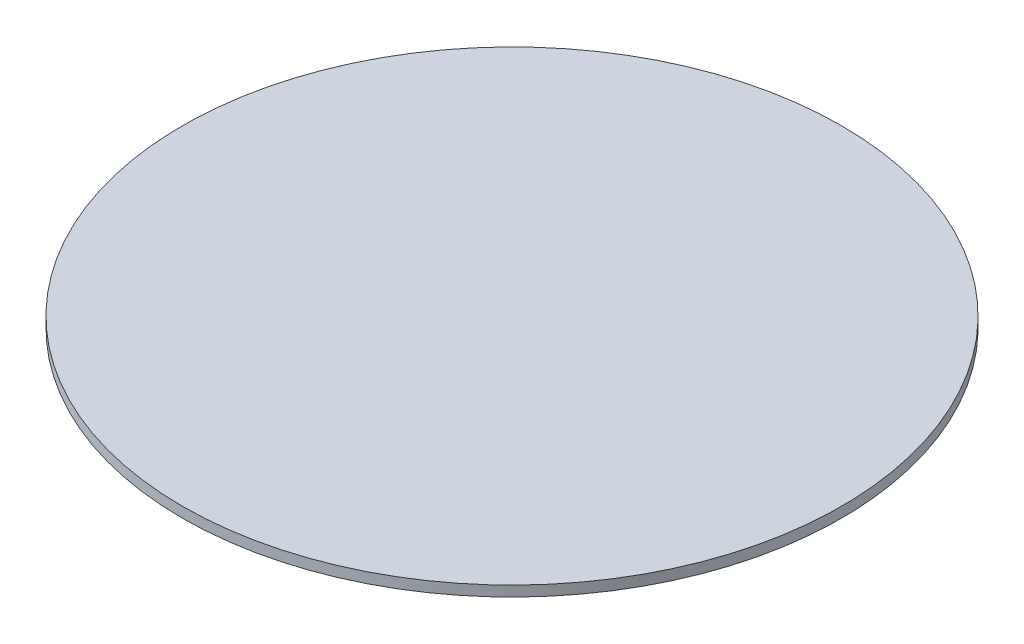
from build123d import *

# Parameters (mm, degrees)
SKETCH1_R           = 158.75
BOSS_EXTRUDE1_DEPTH = 5


with BuildPart() as part:
    # Sketch1 → Boss-Extrude1 (new body)
    with BuildSketch(Plane(origin=(0, 0, 0), x_dir=(1, 0, 0), z_dir=(0, 1, 0))):
        Circle(SKETCH1_R)
    extrude(amount=BOSS_EXTRUDE1_DEPTH)


solid = part.part
